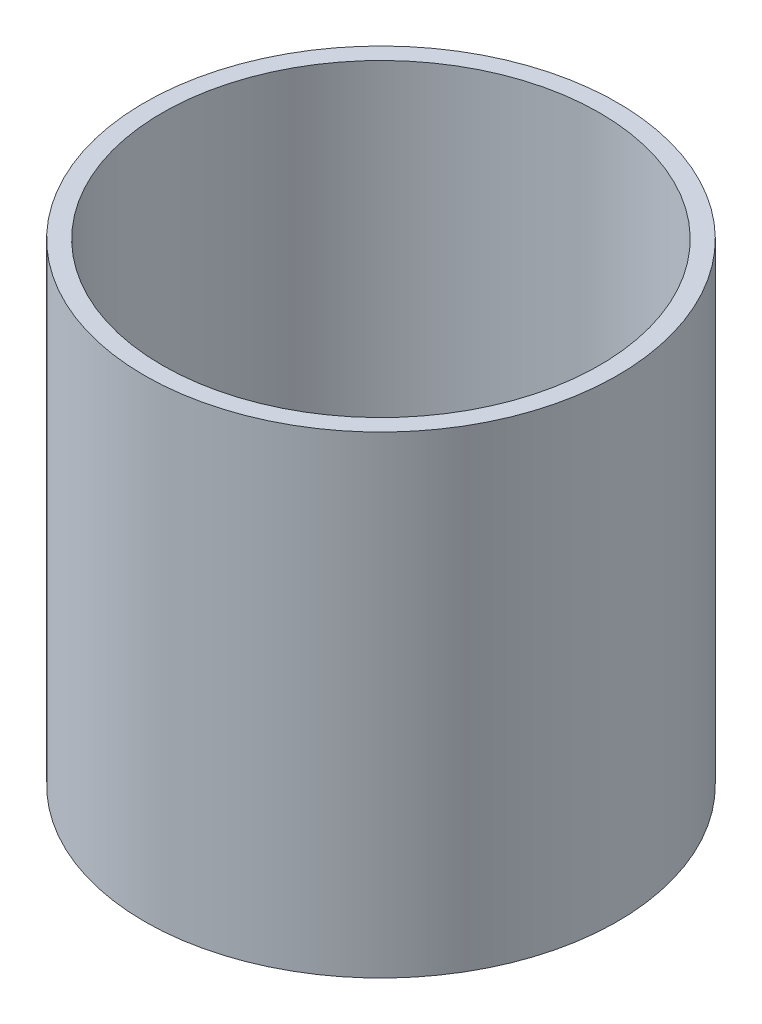
from build123d import *

# Parameters (mm, degrees)
ESQUISSE1_R      = 40
EXTRUSION1_DEPTH = 5
ESQUISSE2_R      = 40
ESQUISSE2_R_2    = 37
EXTRUSION2_DEPTH = 75


with BuildPart() as part:
    # Esquisse1 → Extrusion1 (new body)
    with BuildSketch(Plane(origin=(0, 0, 0), x_dir=(1, 0, 0), z_dir=(0, 1, 0))):
        Circle(ESQUISSE1_R)
    extrude(amount=EXTRUSION1_DEPTH)

    # Esquisse2 → Extrusion2 (add)
    with BuildSketch(Plane(origin=(0, 5, 0), x_dir=(1, 0, 0), z_dir=(0, 1, 0))):
        Circle(ESQUISSE2_R)
        Circle(ESQUISSE2_R_2, mode=Mode.SUBTRACT)
    extrude(amount=EXTRUSION2_DEPTH)


solid = part.part
